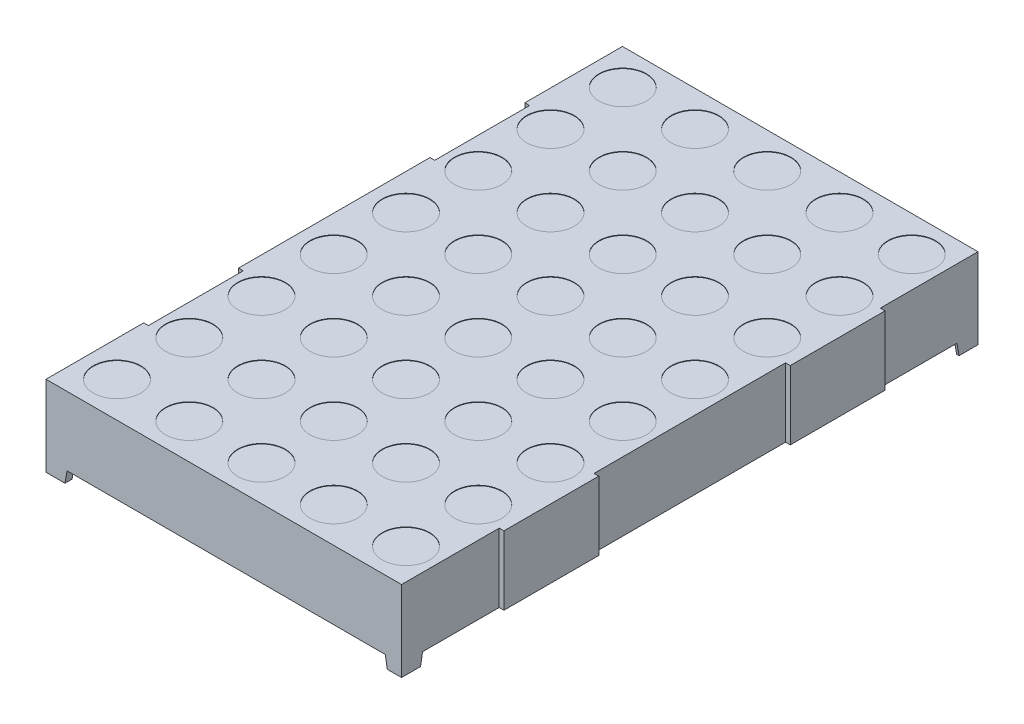
from build123d import *

# Parameters (mm, degrees)
EXTRUDE1_DEPTH     = 19
CUT_EXTRUDE1_DEPTH = 61.8
SKETCH2_R          = 2.5
CUT_EXTRUDE2_DEPTH = 0.05
SKETCH4_R          = 0.25
EXTRUDE2_DEPTH     = 1.25
SKETCH4_3_R        = 0.25
EXTRUDE3_DEPTH     = 4
SKETCH4_4_W        = 1.470408726
SKETCH4_4_H        = 1.470408726
CUT_EXTRUDE3_DEPTH = 1.25
SKETCH2_4_W        = 0.5
SKETCH2_4_H        = 10
SKETCH2_4_H_2      = 10.3
SKETCH2_4_H_3      = 20.2
CUT_EXTRUDE5_DEPTH = 13.5
SKETCH5_W          = 0.025316456
SKETCH5_H          = 0.026582278
SKETCH5_W_2        = 0.025316455
CUT_EXTRUDE6_DEPTH = 0.01


with BuildPart() as part:
    # Sketch1 → Extrude1 (new body, symmetric)
    with BuildSketch(Plane(origin=(0, 0, 0), x_dir=(0, 0, -1), z_dir=(1, 0, 0))):
        Polygon((30.4, 4.25), (-30.4, 4.25), (21.458823529, -3), (28.179591274, -3), (28.34945199, -3.963327992), (30.4, -4.25), align=None)
        Polygon((21.458823529, -3), (-30.4, 4.25), (-30.4, -4.25), (-28.4, -4.25), (-28.179591274, -3), align=None)
        Polygon((30.4, -4.25), (28.34945199, -3.963327992), (28.4, -4.25), align=None)
    extrude(amount=EXTRUDE1_DEPTH, both=True)

    # Sketch3 → Cut-Extrude1 (cut, through all)
    with BuildSketch(Plane.XY.offset(30.4)):
        Polygon((-16.779591274, -3), (-17, -4.25), (17, -4.25), (16.779591274, -3), align=None)
    extrude(amount=-CUT_EXTRUDE1_DEPTH, mode=Mode.SUBTRACT)

    # Sketch2 → Cut-Extrude2 (cut)
    with BuildSketch(Plane(origin=(0, 4.25, 0), x_dir=(-1, 0, 0), z_dir=(0, 1, 0))):
        with Locations(Location((15.24, -19.05, 0), (0, 0, 90))):  # turned: the seam where the file's is
            Circle(SKETCH2_R)
        with Locations(Location((7.62, -19.05, 0), (0, 0, 90))):  # turned: the seam where the file's is
            Circle(SKETCH2_R)
        with Locations(Location((0, -19.05, 0), (0, 0, 90))):  # turned: the seam where the file's is
            Circle(SKETCH2_R)
        with Locations(Location((-7.62, -19.05, 0), (0, 0, 90))):  # turned: the seam where the file's is
            Circle(SKETCH2_R)
        with Locations(Location((-15.24, -19.05, 0), (0, 0, 90))):  # turned: the seam where the file's is
            Circle(SKETCH2_R)
        with Locations(Location((-15.24, -11.43, 0), (0, 0, 90))):  # turned: the seam where the file's is
            Circle(SKETCH2_R)
        with Locations(Location((-7.62, -11.43, 0), (0, 0, 90))):  # turned: the seam where the file's is
            Circle(SKETCH2_R)
        with Locations(Location((0, -11.43, 0), (0, 0, 90))):  # turned: the seam where the file's is
            Circle(SKETCH2_R)
        with Locations(Location((7.62, -11.43, 0), (0, 0, 90))):  # turned: the seam where the file's is
            Circle(SKETCH2_R)
        with Locations(Location((15.24, -11.43, 0), (0, 0, 90))):  # turned: the seam where the file's is
            Circle(SKETCH2_R)
        with Locations(Location((15.24, -3.81, 0), (0, 0, 90))):  # turned: the seam where the file's is
            Circle(SKETCH2_R)
        with Locations(Location((7.62, -3.81, 0), (0, 0, 90))):  # turned: the seam where the file's is
            Circle(SKETCH2_R)
        with Locations(Location((0, -3.81, 0), (0, 0, 90))):  # turned: the seam where the file's is
            Circle(SKETCH2_R)
        with Locations(Location((-7.62, -3.81, 0), (0, 0, 90))):  # turned: the seam where the file's is
            Circle(SKETCH2_R)
        with Locations(Location((-15.24, -3.81, 0), (0, 0, 90))):  # turned: the seam where the file's is
            Circle(SKETCH2_R)
        with Locations(Location((-15.24, 3.81, 0), (0, 0, 90))):  # turned: the seam where the file's is
            Circle(SKETCH2_R)
        with Locations(Location((-7.62, 3.81, 0), (0, 0, 90))):  # turned: the seam where the file's is
            Circle(SKETCH2_R)
        with Locations(Location((0, 3.81, 0), (0, 0, 90))):  # turned: the seam where the file's is
            Circle(SKETCH2_R)
        with Locations(Location((7.62, 3.81, 0), (0, 0, 90))):  # turned: the seam where the file's is
            Circle(SKETCH2_R)
        with Locations(Location((15.24, 3.81, 0), (0, 0, 90))):  # turned: the seam where the file's is
            Circle(SKETCH2_R)
        with Locations(Location((15.24, 11.43, 0), (0, 0, 90))):  # turned: the seam where the file's is
            Circle(SKETCH2_R)
        with Locations(Location((7.62, 11.43, 0), (0, 0, 90))):  # turned: the seam where the file's is
            Circle(SKETCH2_R)
        with Locations(Location((0, 11.43, 0), (0, 0, 90))):  # turned: the seam where the file's is
            Circle(SKETCH2_R)
        with Locations(Location((-7.62, 11.43, 0), (0, 0, 90))):  # turned: the seam where the file's is
            Circle(SKETCH2_R)
        with Locations(Location((-15.24, 11.43, 0), (0, 0, 90))):  # turned: the seam where the file's is
            Circle(SKETCH2_R)
        with Locations(Location((-15.24, 19.05, 0), (0, 0, 90))):  # turned: the seam where the file's is
            Circle(SKETCH2_R)
        with Locations(Location((-7.62, 19.05, 0), (0, 0, 90))):  # turned: the seam where the file's is
            Circle(SKETCH2_R)
        with Locations(Location((0, 19.05, 0), (0, 0, 90))):  # turned: the seam where the file's is
            Circle(SKETCH2_R)
        with Locations(Location((7.62, 19.05, 0), (0, 0, 90))):  # turned: the seam where the file's is
            Circle(SKETCH2_R)
        with Locations(Location((15.24, 19.05, 0), (0, 0, 90))):  # turned: the seam where the file's is
            Circle(SKETCH2_R)
        with Locations(Location((15.24, 26.67, 0), (0, 0, 90))):  # turned: the seam where the file's is
            Circle(SKETCH2_R)
        with Locations(Location((7.62, 26.67, 0), (0, 0, 90))):  # turned: the seam where the file's is
            Circle(SKETCH2_R)
        with Locations(Location((0, 26.67, 0), (0, 0, 90))):  # turned: the seam where the file's is
            Circle(SKETCH2_R)
        with Locations(Location((-7.62, 26.67, 0), (0, 0, 90))):  # turned: the seam where the file's is
            Circle(SKETCH2_R)
        with Locations(Location((-15.24, 26.67, 0), (0, 0, 90))):  # turned: the seam where the file's is
            Circle(SKETCH2_R)
        with Locations(Location((15.24, -26.67, 0), (0, 0, 90))):  # turned: the seam where the file's is
            Circle(SKETCH2_R)
        with Locations(Location((7.62, -26.67, 0), (0, 0, 90))):  # turned: the seam where the file's is
            Circle(SKETCH2_R)
        with Locations(Location((0, -26.67, 0), (0, 0, 90))):  # turned: the seam where the file's is
            Circle(SKETCH2_R)
        with Locations(Location((-7.62, -26.67, 0), (0, 0, 90))):  # turned: the seam where the file's is
            Circle(SKETCH2_R)
        with Locations(Location((-15.24, -26.67, 0), (0, 0, 90))):  # turned: the seam where the file's is
            Circle(SKETCH2_R)
    extrude(amount=-CUT_EXTRUDE2_DEPTH, mode=Mode.SUBTRACT)

    # Sketch4 → Extrude2 (add)
    with BuildSketch(Plane.XZ.offset(4.25)):
        with Locations(Location((-7.62, 22.86, 0), (0, 0, 270))):  # turned: the seam where the file's is
            Circle(SKETCH4_R)
        with Locations(Location((-5.08, 22.86, 0), (0, 0, 270))):  # turned: the seam where the file's is
            Circle(SKETCH4_R)
        with Locations(Location((-2.54, 22.86, 0), (0, 0, 270))):  # turned: the seam where the file's is
            Circle(SKETCH4_R)
        with Locations(Location((7.62, 22.86, 0), (0, 0, 270))):  # turned: the seam where the file's is
            Circle(SKETCH4_R)
        with Locations(Location((0, 22.86, 0), (0, 0, 270))):  # turned: the seam where the file's is
            Circle(SKETCH4_R)
        with Locations(Location((2.54, 22.86, 0), (0, 0, 270))):  # turned: the seam where the file's is
            Circle(SKETCH4_R)
        with Locations(Location((5.08, 22.86, 0), (0, 0, 270))):  # turned: the seam where the file's is
            Circle(SKETCH4_R)
        with Locations(Location((5.08, -22.86, 0), (0, 0, 270))):  # turned: the seam where the file's is
            Circle(SKETCH4_R)
        with Locations(Location((2.54, -22.86, 0), (0, 0, 270))):  # turned: the seam where the file's is
            Circle(SKETCH4_R)
        with Locations(Location((0, -22.86, 0), (0, 0, 270))):  # turned: the seam where the file's is
            Circle(SKETCH4_R)
        with Locations(Location((7.62, -22.86, 0), (0, 0, 270))):  # turned: the seam where the file's is
            Circle(SKETCH4_R)
        with Locations(Location((-2.54, -22.86, 0), (0, 0, 270))):  # turned: the seam where the file's is
            Circle(SKETCH4_R)
        with Locations(Location((-5.08, -22.86, 0), (0, 0, 270))):  # turned: the seam where the file's is
            Circle(SKETCH4_R)
        with Locations(Location((-7.62, -22.86, 0), (0, 0, 270))):  # turned: the seam where the file's is
            Circle(SKETCH4_R)
        with Locations(Location((10.16, 22.86, 0), (0, 0, 270))):  # turned: the seam where the file's is
            Circle(SKETCH4_R)
        with Locations(Location((-10.16, 22.86, 0), (0, 0, 270))):  # turned: the seam where the file's is
            Circle(SKETCH4_R)
        with Locations(Location((-10.16, -22.86, 0), (0, 0, 270))):  # turned: the seam where the file's is
            Circle(SKETCH4_R)
        with Locations(Location((10.16, -22.86, 0), (0, 0, 270))):  # turned: the seam where the file's is
            Circle(SKETCH4_R)
    extrude(amount=-EXTRUDE2_DEPTH)

    # Sketch4_3 → Extrude3 (add)
    with BuildSketch(Plane.XZ.offset(4.25)):
        with Locations(Location((-7.62, 22.86, 0), (0, 0, 270))):  # turned: the seam where the file's is
            Circle(SKETCH4_3_R)
        with Locations(Location((-5.08, 22.86, 0), (0, 0, 270))):  # turned: the seam where the file's is
            Circle(SKETCH4_3_R)
        with Locations(Location((-2.54, 22.86, 0), (0, 0, 270))):  # turned: the seam where the file's is
            Circle(SKETCH4_3_R)
        with Locations(Location((7.62, 22.86, 0), (0, 0, 270))):  # turned: the seam where the file's is
            Circle(SKETCH4_3_R)
        with Locations(Location((0, 22.86, 0), (0, 0, 270))):  # turned: the seam where the file's is
            Circle(SKETCH4_3_R)
        with Locations(Location((2.54, 22.86, 0), (0, 0, 270))):  # turned: the seam where the file's is
            Circle(SKETCH4_3_R)
        with Locations(Location((5.08, 22.86, 0), (0, 0, 270))):  # turned: the seam where the file's is
            Circle(SKETCH4_3_R)
        with Locations(Location((5.08, -22.86, 0), (0, 0, 270))):  # turned: the seam where the file's is
            Circle(SKETCH4_3_R)
        with Locations(Location((2.54, -22.86, 0), (0, 0, 270))):  # turned: the seam where the file's is
            Circle(SKETCH4_3_R)
        with Locations(Location((0, -22.86, 0), (0, 0, 270))):  # turned: the seam where the file's is
            Circle(SKETCH4_3_R)
        with Locations(Location((7.62, -22.86, 0), (0, 0, 270))):  # turned: the seam where the file's is
            Circle(SKETCH4_3_R)
        with Locations(Location((-2.54, -22.86, 0), (0, 0, 270))):  # turned: the seam where the file's is
            Circle(SKETCH4_3_R)
        with Locations(Location((-5.08, -22.86, 0), (0, 0, 270))):  # turned: the seam where the file's is
            Circle(SKETCH4_3_R)
        with Locations(Location((-7.62, -22.86, 0), (0, 0, 270))):  # turned: the seam where the file's is
            Circle(SKETCH4_3_R)
        with Locations(Location((10.16, 22.86, 0), (0, 0, 270))):  # turned: the seam where the file's is
            Circle(SKETCH4_3_R)
        with Locations(Location((-10.16, 22.86, 0), (0, 0, 270))):  # turned: the seam where the file's is
            Circle(SKETCH4_3_R)
        with Locations(Location((-10.16, -22.86, 0), (0, 0, 270))):  # turned: the seam where the file's is
            Circle(SKETCH4_3_R)
        with Locations(Location((10.16, -22.86, 0), (0, 0, 270))):  # turned: the seam where the file's is
            Circle(SKETCH4_3_R)
    extrude(amount=EXTRUDE3_DEPTH)

    # Sketch4_4 → Cut-Extrude3 (cut)
    with BuildSketch(Plane.XZ.offset(4.25)):
        with Locations((-17.514795637, 28.914795637)):
            Rectangle(SKETCH4_4_W, SKETCH4_4_H)
        with Locations((17.514795637, 28.914795637)):
            Rectangle(SKETCH4_4_W, SKETCH4_4_H)
        with Locations((17.514795637, -28.914795637)):
            Rectangle(SKETCH4_4_W, SKETCH4_4_H)
        with Locations((-17.514795637, -28.914795637)):
            Rectangle(SKETCH4_4_W, SKETCH4_4_H)
    extrude(amount=-CUT_EXTRUDE3_DEPTH, mode=Mode.SUBTRACT)

    # Sketch2_4 → Cut-Extrude5 (cut, through all)
    with BuildSketch(Plane(origin=(0, 4.25, 0), x_dir=(-1, 0, 0), z_dir=(0, 1, 0))):
        with Locations((18.75, -15.1)):
            Rectangle(SKETCH2_4_W, SKETCH2_4_H)
        with Locations((18.75, 15.1)):
            Rectangle(SKETCH2_4_W, SKETCH2_4_H)
        with Locations((-18.75, 25.25)):
            Rectangle(SKETCH2_4_W, SKETCH2_4_H_2)
        with Locations((-18.75, 0)):
            Rectangle(SKETCH2_4_W, SKETCH2_4_H_3)
        with Locations((-18.75, -25.25)):
            Rectangle(SKETCH2_4_W, SKETCH2_4_H_2)
    extrude(amount=-CUT_EXTRUDE5_DEPTH, mode=Mode.SUBTRACT)

    # Sketch5 → Cut-Extrude6 (cut)
    with BuildSketch(Plane.XZ.offset(3)):
        Polygon((0.896484083, 19.016590926), (0.919941361, 19.09127447), (0.944684241, 19.09127447), (0.96110038, 19.040938236), (0.976626488, 19.09127447), (1.002358292, 19.09127447), (1.025598007, 19.016590926), (1.000420001, 19.016590926), (0.987425539, 19.068074312), (0.971009399, 19.016590926), (0.949510191, 19.016590926), (0.933192944, 19.068074312), (0.920376488, 19.016590926), align=None)
        Polygon((0.762306868, 19.016590926), (0.785764146, 19.09127447), (0.810507026, 19.09127447), (0.826923165, 19.040938236), (0.842449273, 19.09127447), (0.868181077, 19.09127447), (0.891420792, 19.016590926), (0.866242785, 19.016590926), (0.853248323, 19.068074312), (0.836832184, 19.016590926), (0.815332975, 19.016590926), (0.799015728, 19.068074312), (0.786199273, 19.016590926), align=None)
        Polygon((0.628129653, 19.016590926), (0.651586931, 19.09127447), (0.676329811, 19.09127447), (0.69274595, 19.040938236), (0.708272058, 19.09127447), (0.734003861, 19.09127447), (0.757243577, 19.016590926), (0.73206557, 19.016590926), (0.719071108, 19.068074312), (0.702654969, 19.016590926), (0.68115576, 19.016590926), (0.664838513, 19.068074312), (0.652022058, 19.016590926), align=None)
        with Locations((0.600281551, 19.077983331)):
            Rectangle(SKETCH5_W, SKETCH5_H)
        with BuildLine():
            add(Edge.make_bspline(
                [(0.483825855, 19.060103584), (0.483862383, 19.061325698), (0.483934112, 19.063725522), (0.484543274, 19.067233488), (0.485538799, 19.070556771), (0.486903137, 19.073719487), (0.488717125, 19.076674853), (0.490872138, 19.07949342), (0.493484053, 19.082077382), (0.496421089, 19.084516143), (0.499719017, 19.086698538), (0.503321638, 19.088598676), (0.507191958, 19.090223395), (0.511345979, 19.091555085), (0.515791556, 19.092545852), (0.520509333, 19.093269169), (0.525502682, 19.093742677), (0.52892627, 19.093784618), (0.530681077, 19.093806116)],
                knots=[0, 0, 0, 0, 0.907421153, 1.781872267, 2.635683434, 3.480115191, 4.332689235, 5.205575272, 6.109500117, 7.055808355, 8.037942167, 9.041423561, 10.07750834, 11.152467461, 12.277657752, 13.45734338, 14.696726425, 16, 16, 16, 16], degree=3))
            add(Edge.make_bspline(
                [(0.530681077, 19.093806116), (0.532699061, 19.093778851), (0.536607247, 19.093726047), (0.542274815, 19.093340674), (0.547538282, 19.092652724), (0.552436029, 19.091696144), (0.55704033, 19.090492859), (0.561473674, 19.089202215), (0.565754966, 19.087737634), (0.568528058, 19.086637498), (0.569901804, 19.086092508)],
                knots=[0, 0, 0, 0, 1.203182053, 2.33017619, 3.384818652, 4.366208123, 5.30340534, 6.221361684, 7.118890722, 8, 8, 8, 8], degree=3))
            Line((0.569901804, 19.086092508), (0.569901804, 19.062160546))
            Line((0.569901804, 19.062160546), (0.567053703, 19.062160546))
            add(Edge.make_bspline(
                [(0.567053703, 19.062160546), (0.56568814, 19.063241509), (0.56296503, 19.065397088), (0.558538072, 19.068165442), (0.55387906, 19.070538453), (0.549040667, 19.072521075), (0.544139298, 19.074096689), (0.539270231, 19.075223595), (0.534501248, 19.075962959), (0.531342926, 19.07604452), (0.529791045, 19.076084597)],
                knots=[0, 0, 0, 0, 1.030738938, 2.055426519, 3.085610749, 4.123842265, 5.148648843, 6.130724483, 7.081507926, 8, 8, 8, 8], degree=3))
            add(Edge.make_bspline(
                [(0.529791045, 19.076084597), (0.529362299, 19.076083296), (0.528444386, 19.076080511), (0.526975238, 19.075959196), (0.525318895, 19.075831352), (0.523538157, 19.075635238), (0.521750952, 19.075404093), (0.520090704, 19.075057626), (0.518589943, 19.074688475), (0.517683273, 19.074321209), (0.517251488, 19.074146305)],
                knots=[0, 0, 0, 0, 0.806537132, 1.726733348, 2.77251655, 3.932999672, 5.098049949, 6.161349231, 7.124375527, 8, 8, 8, 8], degree=3))
            add(Edge.make_bspline(
                [(0.517251488, 19.074146305), (0.516772002, 19.07391807), (0.515829709, 19.073469538), (0.514527179, 19.072655628), (0.513356693, 19.071760883), (0.512295991, 19.07079915), (0.511433596, 19.069636162), (0.510812435, 19.068236891), (0.510467864, 19.066587598), (0.510428792, 19.065412437), (0.510408134, 19.064791084)],
                knots=[0, 0, 0, 0, 1.02474257, 2.013837243, 2.958431669, 3.867978675, 4.769292696, 5.732237074, 6.800947934, 8, 8, 8, 8], degree=3))
            add(Edge.make_bspline(
                [(0.510408134, 19.064791084), (0.510439595, 19.064245218), (0.510501457, 19.063171884), (0.511082963, 19.061643454), (0.51196701, 19.060223318), (0.513246426, 19.058957982), (0.514860104, 19.05783187), (0.516791091, 19.056821107), (0.519064941, 19.055985349), (0.520702154, 19.055547477), (0.521563197, 19.055317192)],
                knots=[0, 0, 0, 0, 0.825427492, 1.623033598, 2.45033906, 3.348940377, 4.33183287, 5.428402891, 6.647546779, 8, 8, 8, 8], degree=3))
            add(Edge.make_bspline(
                [(0.521563197, 19.055317192), (0.523532438, 19.054871987), (0.527567649, 19.053959709), (0.533707462, 19.052772255), (0.539846165, 19.051546384), (0.543802422, 19.050332069), (0.545732501, 19.04973966)],
                knots=[0, 0, 0, 0, 0.976118991, 2.000185432, 3.024380873, 4, 4, 4, 4], degree=3))
            add(Edge.make_bspline(
                [(0.545732501, 19.04973966), (0.546770653, 19.049385937), (0.548791515, 19.048697383), (0.551690707, 19.047544734), (0.554333955, 19.0462396), (0.556791494, 19.044917562), (0.558984158, 19.043437504), (0.560978792, 19.041904745), (0.562731453, 19.04025194), (0.56425789, 19.038502448), (0.565600756, 19.036666086), (0.566754166, 19.034718945), (0.567715189, 19.032652495), (0.56853858, 19.030497098), (0.569149807, 19.028222563), (0.569572243, 19.025846146), (0.569870306, 19.023362659), (0.569891162, 19.021668324), (0.569901804, 19.020803742)],
                knots=[0, 0, 0, 0, 1.287376879, 2.505999703, 3.65855109, 4.746193839, 5.778582289, 6.760029101, 7.696159662, 8.601061861, 9.48181646, 10.363080883, 11.252765705, 12.153987336, 13.068239035, 14.012364187, 14.985753787, 16, 16, 16, 16], degree=3))
            add(Edge.make_bspline(
                [(0.569901804, 19.020803742), (0.569864504, 19.019647596), (0.569791098, 19.017372321), (0.569189647, 19.014043299), (0.568163137, 19.01089448), (0.566776777, 19.007891324), (0.564949284, 19.00507706), (0.562757162, 19.002399574), (0.560146851, 18.999907078), (0.557161524, 18.997608441), (0.553874677, 18.995529636), (0.550340672, 18.993692928), (0.54656182, 18.992186481), (0.542581935, 18.99090525), (0.538362543, 18.989952854), (0.533925572, 18.989233277), (0.52925171, 18.988820276), (0.526060299, 18.988769001), (0.524431077, 18.988742824)],
                knots=[0, 0, 0, 0, 0.894901293, 1.761149761, 2.608783409, 3.453876344, 4.314933854, 5.200038827, 6.12799933, 7.103249695, 8.113098521, 9.136064399, 10.182719798, 11.259667356, 12.370545059, 13.528828137, 14.738461593, 16, 16, 16, 16], degree=3))
            add(Edge.make_bspline(
                [(0.524431077, 18.988742824), (0.522762425, 18.988765217), (0.519427951, 18.988809965), (0.514445978, 18.989184934), (0.509488564, 18.989751436), (0.504617, 18.99055089), (0.499934492, 18.991568546), (0.495517879, 18.992654504), (0.491438908, 18.993894894), (0.488865183, 18.994848939), (0.487623323, 18.99530928)],
                knots=[0, 0, 0, 0, 1.065379838, 2.128953261, 3.188461447, 4.250817766, 5.279613205, 6.247547721, 7.154416075, 8, 8, 8, 8], degree=3))
            Line((0.487623323, 18.99530928), (0.487623323, 19.017856749))
            Line((0.487623323, 19.017856749), (0.490451646, 19.017856749))
            add(Edge.make_bspline(
                [(0.490451646, 19.017856749), (0.491524606, 19.017056545), (0.493718836, 19.015420107), (0.497377589, 19.01333413), (0.501341649, 19.011384616), (0.505606551, 19.009662823), (0.510079091, 19.008242222), (0.514656637, 19.007213178), (0.519283702, 19.006574055), (0.522385293, 19.006500922), (0.523936615, 19.006464343)],
                knots=[0, 0, 0, 0, 0.89224925, 1.824673196, 2.804309561, 3.838364047, 4.890042674, 5.931526337, 6.965412421, 8, 8, 8, 8], degree=3))
            add(Edge.make_bspline(
                [(0.523936615, 19.006464343), (0.525031914, 19.006488553), (0.52722166, 19.006536954), (0.530496067, 19.006886208), (0.533730859, 19.007557949), (0.535773757, 19.008372286), (0.536792627, 19.008778426)],
                knots=[0, 0, 0, 0, 0.998993879, 1.997209027, 3.00113285, 4, 4, 4, 4], degree=3))
            add(Edge.make_bspline(
                [(0.536792627, 19.008778426), (0.537226106, 19.008979908), (0.538092776, 19.00938274), (0.539299779, 19.010155065), (0.540403083, 19.011084783), (0.541404088, 19.012137177), (0.542252144, 19.013306512), (0.542889804, 19.014576271), (0.543250624, 19.01593825), (0.54329646, 19.016872418), (0.543319526, 19.017342508)],
                knots=[0, 0, 0, 0, 1.005454979, 2.010239304, 3.005296729, 4.036100111, 5.060531193, 6.034954812, 7.011155677, 8, 8, 8, 8], degree=3))
            add(Edge.make_bspline(
                [(0.543319526, 19.017342508), (0.543284732, 19.017980439), (0.543218243, 19.019199467), (0.542618245, 19.020913163), (0.541620576, 19.022376275), (0.540467478, 19.023369268), (0.539350498, 19.024068028), (0.538309981, 19.024573268), (0.53711053, 19.025086691), (0.535733081, 19.025575888), (0.534197946, 19.026069934), (0.532489024, 19.026544604), (0.530606417, 19.026994163), (0.529290526, 19.027280315), (0.528604336, 19.027429533)],
                knots=[0, 0, 0, 0, 1.174343879, 2.244064321, 3.303704314, 4.407076671, 5.02483983, 5.732197225, 6.53898402, 7.431906431, 8.428480183, 9.514816237, 10.704066255, 12, 12, 12, 12], degree=3))
            add(Edge.make_bspline(
                [(0.528604336, 19.027429533), (0.526771711, 19.027806253), (0.523171009, 19.028546425), (0.517765933, 19.029640722), (0.512272879, 19.030953239), (0.508602329, 19.032082452), (0.506689779, 19.032670831)],
                knots=[0, 0, 0, 0, 0.995788186, 1.956503735, 2.935230479, 4, 4, 4, 4], degree=3))
            add(Edge.make_bspline(
                [(0.506689779, 19.032670831), (0.505743223, 19.032990072), (0.503891605, 19.03361456), (0.501251007, 19.034700878), (0.498803834, 19.035874735), (0.4965372, 19.037116705), (0.494461834, 19.038459138), (0.492575544, 19.039884471), (0.490877587, 19.041389254), (0.489388839, 19.043004974), (0.488060081, 19.044715322), (0.486947738, 19.046565935), (0.485952152, 19.048509464), (0.485198997, 19.050602907), (0.484574488, 19.052801435), (0.484152745, 19.055133369), (0.483858382, 19.057577587), (0.483836818, 19.059252186), (0.483825855, 19.060103584)],
                knots=[0, 0, 0, 0, 1.237326419, 2.420410185, 3.534642089, 4.598489486, 5.620241961, 6.59385002, 7.525152549, 8.426792174, 9.312230456, 10.203151844, 11.098070343, 12.012931196, 12.954244379, 13.926618287, 14.945853925, 16, 16, 16, 16], degree=3))
        make_face()
        with BuildLine():
            Line((0.391420792, 19.09127447), (0.415471425, 19.09127447))
            Line((0.415471425, 19.09127447), (0.415471425, 19.083442192))
            add(Edge.make_bspline(
                [(0.415471425, 19.083442192), (0.416564618, 19.084250986), (0.41867228, 19.085810331), (0.421846839, 19.087887393), (0.424865139, 19.089671815), (0.427795491, 19.091194932), (0.430801768, 19.092407103), (0.434039903, 19.093225484), (0.437541498, 19.093728208), (0.439968568, 19.093779569), (0.441223007, 19.093806116)],
                knots=[0, 0, 0, 0, 1.150945962, 2.219006967, 3.209666795, 4.118194914, 5.012574058, 5.946577101, 6.93868214, 8, 8, 8, 8], degree=3))
            add(Edge.make_bspline(
                [(0.441223007, 19.093806116), (0.442239282, 19.093783168), (0.444218263, 19.093738482), (0.447096562, 19.093396761), (0.449798529, 19.092848352), (0.452327365, 19.092079945), (0.454677065, 19.091076914), (0.456820745, 19.08980528), (0.458823322, 19.088372566), (0.460605269, 19.0866662), (0.462220816, 19.084768282), (0.463603386, 19.082635873), (0.464781091, 19.080302933), (0.465722191, 19.077751083), (0.46647728, 19.074992779), (0.467001212, 19.072013531), (0.467321805, 19.068826404), (0.467353744, 19.066631274), (0.467370159, 19.065503109)],
                knots=[0, 0, 0, 0, 1.108959949, 2.159465255, 3.158589008, 4.114545495, 5.039534357, 5.93921201, 6.830099133, 7.720870013, 8.624681761, 9.544731627, 10.487599671, 11.471264588, 12.508152322, 13.604835107, 14.769030043, 16, 16, 16, 16], degree=3))
            Line((0.467370159, 19.065503109), (0.467370159, 19.016590926))
            Line((0.467370159, 19.016590926), (0.443319526, 19.016590926))
            Line((0.443319526, 19.016590926), (0.443319526, 19.05417004))
            add(Edge.make_bspline(
                [(0.443319526, 19.05417004), (0.44331789, 19.055086511), (0.44331476, 19.056840726), (0.443232421, 19.059346533), (0.44311152, 19.061614705), (0.442972816, 19.063656734), (0.442719799, 19.065503485), (0.44234209, 19.067169646), (0.441871264, 19.068689248), (0.441406946, 19.069595949), (0.44118345, 19.070032381)],
                knots=[0, 0, 0, 0, 1.361401701, 2.605856924, 3.723918663, 4.735739235, 5.645738665, 6.489217889, 7.27279937, 8, 8, 8, 8], degree=3))
            add(Edge.make_bspline(
                [(0.44118345, 19.070032381), (0.440953442, 19.070431087), (0.440501265, 19.071214908), (0.439581, 19.07222122), (0.438502158, 19.07306497), (0.437224954, 19.073723071), (0.435735387, 19.074213574), (0.434014529, 19.074594145), (0.432022787, 19.074766023), (0.430615319, 19.074800513), (0.429870159, 19.074818774)],
                knots=[0, 0, 0, 0, 0.849004071, 1.669068917, 2.503060811, 3.370079215, 4.310762265, 5.396376419, 6.621555549, 8, 8, 8, 8], degree=3))
            add(Edge.make_bspline(
                [(0.429870159, 19.074818774), (0.429329216, 19.074798935), (0.4282178, 19.074758173), (0.426500347, 19.074566632), (0.424711087, 19.074167474), (0.422192418, 19.073522529), (0.419027209, 19.072328675), (0.416667675, 19.070975528), (0.415471425, 19.070289502)],
                knots=[0, 0, 0, 0, 0.638062719, 1.310959128, 2.033463623, 2.796942592, 4.376095945, 6, 6, 6, 6], degree=3))
            Line((0.415471425, 19.070289502), (0.415471425, 19.016590926))
            Line((0.415471425, 19.016590926), (0.391420792, 19.016590926))
            Line((0.391420792, 19.016590926), (0.391420792, 19.09127447))
        make_face()
        with BuildLine():
            Line((0.293952437, 19.09127447), (0.31800307, 19.09127447))
            Line((0.31800307, 19.09127447), (0.31800307, 19.053695356))
            add(Edge.make_bspline(
                [(0.31800307, 19.053695356), (0.318028077, 19.052165367), (0.318078048, 19.049107875), (0.318354599, 19.045344781), (0.318739086, 19.042503242), (0.319106626, 19.040671653), (0.319538497, 19.039123536), (0.319950758, 19.038237775), (0.320139146, 19.037833014)],
                knots=[0, 0, 0, 0, 1.709111167, 3.415443484, 4.21113913, 4.910175115, 5.501990373, 6, 6, 6, 6], degree=3))
            add(Edge.make_bspline(
                [(0.320139146, 19.037833014), (0.320383607, 19.037434951), (0.320862907, 19.036654493), (0.321800258, 19.035641617), (0.322894041, 19.034812248), (0.324165217, 19.034132781), (0.325653326, 19.033653593), (0.327377244, 19.033300839), (0.329357428, 19.033090285), (0.330766257, 19.033061732), (0.331511773, 19.033046622)],
                knots=[0, 0, 0, 0, 0.860202684, 1.686548532, 2.528236983, 3.382486038, 4.33249885, 5.401154041, 6.624757403, 8, 8, 8, 8], degree=3))
            add(Edge.make_bspline(
                [(0.331511773, 19.033046622), (0.332642662, 19.033106723), (0.334950357, 19.033229364), (0.337825667, 19.03389603), (0.340143005, 19.034755994), (0.342000722, 19.03550643), (0.343908444, 19.036480531), (0.345187986, 19.037201972), (0.345851172, 19.037575894)],
                knots=[0, 0, 0, 0, 1.33818541, 2.730705359, 3.468371228, 4.262126284, 5.099261778, 6, 6, 6, 6], degree=3))
            Line((0.345851172, 19.037575894), (0.345851172, 19.09127447))
            Line((0.345851172, 19.09127447), (0.369901804, 19.09127447))
            Line((0.369901804, 19.09127447), (0.369901804, 19.016590926))
            Line((0.369901804, 19.016590926), (0.345851172, 19.016590926))
            Line((0.345851172, 19.016590926), (0.345851172, 19.024423204))
            add(Edge.make_bspline(
                [(0.345851172, 19.024423204), (0.344793765, 19.023617053), (0.34273546, 19.02204783), (0.339556223, 19.02000741), (0.336472325, 19.018208641), (0.333419315, 19.016695824), (0.33030436, 19.015489049), (0.327041601, 19.01467806), (0.323625195, 19.014134257), (0.32128848, 19.014084564), (0.320099589, 19.01405928)],
                knots=[0, 0, 0, 0, 1.126119141, 2.192057864, 3.198061997, 4.149848529, 5.076251285, 6.021887753, 6.99356175, 8, 8, 8, 8], degree=3))
            add(Edge.make_bspline(
                [(0.320099589, 19.01405928), (0.319103324, 19.014084681), (0.317158438, 19.014134267), (0.314323588, 19.014443819), (0.311652482, 19.014995041), (0.309159098, 19.015790898), (0.306823411, 19.016782257), (0.304649739, 19.017986237), (0.30266389, 19.019449518), (0.300835738, 19.021109456), (0.299196638, 19.023000754), (0.297799729, 19.025130132), (0.296595367, 19.027467052), (0.295646101, 19.030029689), (0.294854777, 19.032795961), (0.294350014, 19.035794591), (0.293992361, 19.039004477), (0.293966011, 19.041220627), (0.293952437, 19.042362286)],
                knots=[0, 0, 0, 0, 1.08828964, 2.12453497, 3.110382522, 4.062402335, 4.978696626, 5.878225494, 6.769849763, 7.667011675, 8.57076823, 9.495541561, 10.442454184, 11.436213583, 12.475881554, 13.580560132, 14.753614518, 16, 16, 16, 16], degree=3))
            Line((0.293952437, 19.042362286), (0.293952437, 19.09127447))
        make_face()
        Polygon((0.199015728, 19.09127447), (0.271167627, 19.09127447), (0.271167627, 18.99127447), (0.245851172, 18.99127447), (0.245851172, 19.072287128), (0.199015728, 19.072287128), align=None)
        Polygon((0.111673956, 19.09127447), (0.183825855, 19.09127447), (0.183825855, 18.99127447), (0.111673956, 18.99127447), (0.111673956, 19.010261812), (0.158509399, 19.010261812), (0.158509399, 19.027983331), (0.115471425, 19.027983331), (0.115471425, 19.046970673), (0.158509399, 19.046970673), (0.158509399, 19.072287128), (0.111673956, 19.072287128), align=None)
        with BuildLine():
            add(Edge.make_bspline(
                [(-0.00478174, 19.041373362), (-0.004762425, 19.042521051), (-0.004724172, 19.044793937), (-0.004428981, 19.048158744), (-0.003902956, 19.05142442), (-0.003223774, 19.054608668), (-0.002301269, 19.057687596), (-0.001219555, 19.060695173), (9.0091e-05, 19.063600666), (0.001594944, 19.066402101), (0.003244416, 19.069074204), (0.005019165, 19.071594412), (0.006864944, 19.07397763), (0.008854257, 19.076172524), (0.010933438, 19.078214544), (0.013108967, 19.080105358), (0.015414031, 19.081808789), (0.017021194, 19.082831673), (0.017825064, 19.083343299)],
                knots=[0, 0, 0, 0, 1.105570398, 2.18947457, 3.250358341, 4.290584537, 5.323553275, 6.344225964, 7.367641686, 8.3905646, 9.405808457, 10.390761353, 11.358902336, 12.307789878, 13.241960776, 14.165076779, 15.082208636, 16, 16, 16, 16], degree=3))
            add(Edge.make_bspline(
                [(0.017825064, 19.083343299), (0.019064251, 19.08405562), (0.021548948, 19.085483897), (0.025533406, 19.087149736), (0.029655015, 19.088563959), (0.034014196, 19.0895774), (0.038652917, 19.090347235), (0.043657728, 19.090895406), (0.049064635, 19.091200909), (0.052799627, 19.091249391), (0.054731709, 19.09127447)],
                knots=[0, 0, 0, 0, 0.896321744, 1.797216976, 2.705381885, 3.628777036, 4.602292017, 5.655629376, 6.787275635, 8, 8, 8, 8], degree=3))
            Line((0.054731709, 19.09127447), (0.090154969, 19.09127447))
            Line((0.090154969, 19.09127447), (0.090154969, 18.99127447))
            Line((0.090154969, 18.99127447), (0.053723007, 18.99127447))
            add(Edge.make_bspline(
                [(0.053723007, 18.99127447), (0.051744311, 18.99129128), (0.047927651, 18.991323705), (0.042410335, 18.991738632), (0.037307997, 18.992344395), (0.032618417, 18.993238581), (0.028315967, 18.994353162), (0.024398676, 18.995741693), (0.020782442, 18.99723431), (0.018603907, 18.998508864), (0.017548165, 18.999126527)],
                knots=[0, 0, 0, 0, 1.267083275, 2.444046388, 3.541868212, 4.55639609, 5.499737919, 6.385160515, 7.217431253, 8, 8, 8, 8], degree=3))
            add(Edge.make_bspline(
                [(0.017548165, 18.999126527), (0.016697212, 18.999663068), (0.015005087, 19.000729981), (0.012603873, 19.002511834), (0.010374445, 19.00446791), (0.008245943, 19.006519729), (0.006266125, 19.008722616), (0.004422925, 19.011061323), (0.002719108, 19.013539417), (0.001161145, 19.016148886), (-0.00025967, 19.018878938), (-0.001448976, 19.021751997), (-0.002498325, 19.024730527), (-0.003303861, 19.027839489), (-0.004001776, 19.031047326), (-0.00443651, 19.03438867), (-0.004723121, 19.037841158), (-0.004762036, 19.040186048), (-0.00478174, 19.041373362)],
                knots=[0, 0, 0, 0, 0.964065863, 1.917049184, 2.86229036, 3.805247319, 4.749389377, 5.698846072, 6.657678277, 7.629829384, 8.610569287, 9.604676042, 10.607940105, 11.6349849, 12.681042988, 13.752616828, 14.862056989, 16, 16, 16, 16], degree=3))
        make_face()
        with BuildLine():
            add(Edge.make_bspline(
                [(0.021800539, 19.041215135), (0.021843841, 19.039636704), (0.021927454, 19.036588905), (0.022632848, 19.032193261), (0.023772098, 19.028150311), (0.025109791, 19.025037895), (0.026447182, 19.022764577), (0.027574706, 19.021166307), (0.028824372, 19.019652107), (0.030214981, 19.018243267), (0.031750165, 19.016936231), (0.033411424, 19.01570732), (0.035211465, 19.014578675), (0.036484497, 19.013918669), (0.037128861, 19.013584597)],
                knots=[0, 0, 0, 0, 1.694683197, 3.272273219, 4.767406206, 6.197615014, 6.895990032, 7.597410435, 8.296503208, 9.002591366, 9.720792421, 10.460154445, 11.220583224, 12, 12, 12, 12], degree=3))
            add(Edge.make_bspline(
                [(0.037128861, 19.013584597), (0.037803796, 19.013278082), (0.039141565, 19.01267055), (0.04121184, 19.011936463), (0.043304542, 19.011374136), (0.045498769, 19.010901713), (0.047975529, 19.010624577), (0.05089802, 19.010411901), (0.054354693, 19.010274973), (0.056841289, 19.010266402), (0.058173165, 19.010261812)],
                knots=[0, 0, 0, 0, 0.826913061, 1.638999358, 2.447478739, 3.243919028, 4.140906711, 5.225381046, 6.513851968, 8, 8, 8, 8], degree=3))
            Line((0.058173165, 19.010261812), (0.064838513, 19.010261812))
            Line((0.064838513, 19.010261812), (0.064838513, 19.072287128))
            Line((0.064838513, 19.072287128), (0.058173165, 19.072287128))
            add(Edge.make_bspline(
                [(0.058173165, 19.072287128), (0.057414974, 19.072282083), (0.055951239, 19.072272342), (0.053834785, 19.072233239), (0.051870024, 19.072172922), (0.050062673, 19.07210108), (0.048406536, 19.071986177), (0.046918702, 19.07181758), (0.045576352, 19.071673193), (0.044008718, 19.071406073), (0.042155569, 19.070989618), (0.039994303, 19.070311526), (0.03785377, 19.069461107), (0.036465197, 19.068776143), (0.035764146, 19.068430324)],
                knots=[0, 0, 0, 0, 1.186775798, 2.291144404, 3.313233901, 4.263515562, 5.122260739, 5.910868134, 6.60717912, 7.234883681, 8.398964994, 9.577230746, 10.776813768, 12, 12, 12, 12], degree=3))
            add(Edge.make_bspline(
                [(0.035764146, 19.068430324), (0.035180432, 19.068086848), (0.034032495, 19.067411364), (0.032388351, 19.066305502), (0.030901611, 19.065070502), (0.02949555, 19.063787404), (0.028242683, 19.06239695), (0.02706939, 19.06094647), (0.026059134, 19.059384077), (0.024814139, 19.057190548), (0.023594407, 19.054157178), (0.022553647, 19.050190635), (0.021917132, 19.045830625), (0.021840399, 19.042793043), (0.021800539, 19.041215135)],
                knots=[0, 0, 0, 0, 0.755109416, 1.485004392, 2.205961541, 2.908125208, 3.605307969, 4.290649036, 4.985852759, 5.676964147, 7.100721462, 8.614478074, 10.241350405, 12, 12, 12, 12], degree=3))
        make_face(mode=Mode.SUBTRACT)
        with Locations((-0.03642731, 19.077983331)):
            Rectangle(SKETCH5_W_2, SKETCH5_H)
        with BuildLine():
            add(Edge.make_bspline(
                [(-0.111071297, 19.093806116), (-0.109481191, 19.093784289), (-0.106360069, 19.093741448), (-0.101788625, 19.093264746), (-0.097423821, 19.092546279), (-0.093276203, 19.091528107), (-0.089369642, 19.090171765), (-0.085688588, 19.08855375), (-0.082299226, 19.086535944), (-0.080235496, 19.084959003), (-0.079208164, 19.084173995)],
                knots=[0, 0, 0, 0, 1.123606455, 2.205459211, 3.245124445, 4.248821949, 5.220056174, 6.165006393, 7.086533249, 8, 8, 8, 8], degree=3))
            add(Edge.make_bspline(
                [(-0.079208164, 19.084173995), (-0.078256416, 19.083319221), (-0.076356602, 19.081612978), (-0.073890669, 19.078641551), (-0.071767583, 19.075358507), (-0.06998203, 19.071756285), (-0.068551107, 19.067839556), (-0.067527973, 19.063594894), (-0.066908727, 19.059034113), (-0.066841562, 19.05588618), (-0.066807056, 19.054268932)],
                knots=[0, 0, 0, 0, 0.916457077, 1.82937027, 2.759194969, 3.714948755, 4.706655623, 5.743329475, 6.840637961, 8, 8, 8, 8], degree=3))
            add(Edge.make_bspline(
                [(-0.066807056, 19.054268932), (-0.066845817, 19.052565705), (-0.06692094, 19.049264625), (-0.067584699, 19.044492437), (-0.068654311, 19.040074757), (-0.07019187, 19.036022848), (-0.072122312, 19.032329657), (-0.074386804, 19.028957822), (-0.07700733, 19.025914898), (-0.079014468, 19.024169458), (-0.080019082, 19.023295831)],
                knots=[0, 0, 0, 0, 1.171797512, 2.271099083, 3.308930235, 4.294129479, 5.24602549, 6.17106565, 7.084581485, 8, 8, 8, 8], degree=3))
            add(Edge.make_bspline(
                [(-0.080019082, 19.023295831), (-0.081044995, 19.022527369), (-0.083109214, 19.020981165), (-0.086512058, 19.019078554), (-0.090139748, 19.01749036), (-0.093961483, 19.016213641), (-0.097936469, 19.015259024), (-0.102000023, 19.014566358), (-0.106143825, 19.014137676), (-0.108934205, 19.014085538), (-0.110339493, 19.01405928)],
                knots=[0, 0, 0, 0, 0.952046378, 1.915591786, 2.889970712, 3.892742799, 4.906722985, 5.925995921, 6.955492795, 8, 8, 8, 8], degree=3))
            add(Edge.make_bspline(
                [(-0.110339493, 19.01405928), (-0.111586297, 19.014075678), (-0.114037937, 19.014107921), (-0.117636778, 19.014438524), (-0.121094736, 19.014940462), (-0.124401655, 19.015679034), (-0.127568651, 19.016600651), (-0.130622791, 19.017632713), (-0.133582023, 19.018767944), (-0.135482668, 19.019652221), (-0.136427309, 19.020091717)],
                knots=[0, 0, 0, 0, 1.107549047, 2.177816721, 3.208424937, 4.210433793, 5.185680559, 6.13785309, 7.074491882, 8, 8, 8, 8], degree=3))
            Line((-0.136427309, 19.020091717), (-0.136427309, 19.040641559))
            Line((-0.136427309, 19.040641559), (-0.133084746, 19.040641559))
            add(Edge.make_bspline(
                [(-0.133084746, 19.040641559), (-0.132584168, 19.040225672), (-0.131499144, 19.03932422), (-0.129732312, 19.037877632), (-0.127561992, 19.036377342), (-0.125914963, 19.035482717), (-0.125034904, 19.035004692)],
                knots=[0, 0, 0, 0, 0.792743043, 1.718305972, 2.780820752, 4, 4, 4, 4], degree=3))
            add(Edge.make_bspline(
                [(-0.125034904, 19.035004692), (-0.124105969, 19.034566053), (-0.12220006, 19.033666093), (-0.119656852, 19.032788705), (-0.117453673, 19.032263336), (-0.115640013, 19.031997771), (-0.113705716, 19.031810912), (-0.11237057, 19.031791021), (-0.11168443, 19.031780799)],
                knots=[0, 0, 0, 0, 1.332360773, 2.733622135, 3.480580446, 4.268165618, 5.10999921, 6, 6, 6, 6], degree=3))
            add(Edge.make_bspline(
                [(-0.11168443, 19.031780799), (-0.110918791, 19.03180013), (-0.109435018, 19.031837592), (-0.107274651, 19.03211764), (-0.105250033, 19.032585732), (-0.103361995, 19.033263676), (-0.101608164, 19.034115443), (-0.09998814, 19.035156888), (-0.098494708, 19.036380159), (-0.097175767, 19.037821791), (-0.095982953, 19.039401531), (-0.094963775, 19.041135699), (-0.094051313, 19.042982283), (-0.093356376, 19.044986736), (-0.092796638, 19.047115511), (-0.092407708, 19.049378631), (-0.092165749, 19.051778141), (-0.092137832, 19.053424449), (-0.092123512, 19.054268932)],
                knots=[0, 0, 0, 0, 1.087372478, 2.107277257, 3.088614887, 4.033572876, 4.950837204, 5.852283781, 6.763600506, 7.684681617, 8.621202104, 9.570420019, 10.537986648, 11.542161979, 12.577980734, 13.661919757, 14.800668594, 16, 16, 16, 16], degree=3))
            add(Edge.make_bspline(
                [(-0.092123512, 19.054268932), (-0.092138286, 19.055133088), (-0.092166992, 19.056812101), (-0.092400507, 19.059253712), (-0.092816398, 19.061535143), (-0.093387646, 19.063660463), (-0.094111994, 19.065626481), (-0.095017111, 19.067423878), (-0.096053467, 19.069080685), (-0.097298025, 19.070543297), (-0.098661909, 19.071859619), (-0.100176801, 19.072995753), (-0.10183604, 19.073943898), (-0.10361822, 19.074748361), (-0.105551261, 19.075326759), (-0.107607798, 19.075763451), (-0.109797353, 19.076052008), (-0.111307707, 19.076073571), (-0.112079999, 19.076084597)],
                knots=[0, 0, 0, 0, 1.230336593, 2.390482092, 3.487897344, 4.52859895, 5.520747884, 6.465347575, 7.38981449, 8.296085817, 9.192433006, 10.084246191, 10.984321635, 11.908883871, 12.862027947, 13.850751296, 14.901019963, 16, 16, 16, 16], degree=3))
            add(Edge.make_bspline(
                [(-0.112079999, 19.076084597), (-0.112805764, 19.076075847), (-0.114220616, 19.07605879), (-0.116287616, 19.075849236), (-0.118245121, 19.075542464), (-0.120078263, 19.075102511), (-0.121780995, 19.07458996), (-0.12333733, 19.074017015), (-0.124750305, 19.073413889), (-0.125611595, 19.072946133), (-0.126023828, 19.072722255)],
                knots=[0, 0, 0, 0, 1.201052708, 2.34140671, 3.435973211, 4.479046096, 5.459661032, 6.378175262, 7.223757638, 8, 8, 8, 8], degree=3))
            add(Edge.make_bspline(
                [(-0.126023828, 19.072722255), (-0.126724034, 19.07229236), (-0.128078601, 19.071460718), (-0.129917329, 19.070059152), (-0.131562198, 19.068644893), (-0.132586709, 19.067688675), (-0.133084746, 19.067223837)],
                knots=[0, 0, 0, 0, 1.098601379, 2.125273733, 3.088655601, 4, 4, 4, 4], degree=3))
            Line((-0.133084746, 19.067223837), (-0.136427309, 19.067223837))
            Line((-0.136427309, 19.067223837), (-0.136427309, 19.087931907))
            add(Edge.make_bspline(
                [(-0.136427309, 19.087931907), (-0.13548192, 19.088369401), (-0.133590912, 19.089244495), (-0.130676333, 19.090398366), (-0.127688361, 19.091366527), (-0.124639988, 19.092269607), (-0.121467904, 19.092957969), (-0.118144874, 19.093451092), (-0.114663375, 19.093752004), (-0.112284987, 19.093787833), (-0.111071297, 19.093806116)],
                knots=[0, 0, 0, 0, 0.952012952, 1.904254716, 2.862729541, 3.822037426, 4.808956931, 5.82647221, 6.890850784, 8, 8, 8, 8], degree=3))
        make_face()
        with BuildLine():
            add(Edge.make_bspline(
                [(-0.228832373, 19.053972255), (-0.228807677, 19.055477161), (-0.228759539, 19.058410627), (-0.228220222, 19.062682418), (-0.227407443, 19.066718416), (-0.226234911, 19.070505624), (-0.224754519, 19.074062899), (-0.22290358, 19.077352691), (-0.220732575, 19.080405921), (-0.218241538, 19.083195806), (-0.215440336, 19.085694316), (-0.212366154, 19.087889569), (-0.208992327, 19.089703011), (-0.205378016, 19.091215101), (-0.201493364, 19.092384336), (-0.197339145, 19.093197054), (-0.19292201, 19.093732524), (-0.189883592, 19.093781176), (-0.188326044, 19.093806116)],
                knots=[0, 0, 0, 0, 1.120167703, 2.183507516, 3.201345984, 4.182878364, 5.131270247, 6.065524964, 6.98789854, 7.91635504, 8.84481154, 9.778033504, 10.722808862, 11.691211189, 12.691525459, 13.738229926, 14.840575679, 16, 16, 16, 16], degree=3))
            add(Edge.make_bspline(
                [(-0.188326044, 19.093806116), (-0.186768522, 19.093781094), (-0.183730157, 19.093732281), (-0.179312647, 19.09319795), (-0.175153553, 19.092379999), (-0.171264246, 19.091223898), (-0.1676555, 19.089697349), (-0.164285633, 19.087890301), (-0.161211868, 19.085694108), (-0.158410382, 19.083195916), (-0.155920064, 19.080405689), (-0.153746473, 19.077353507), (-0.151904059, 19.074057553), (-0.150386205, 19.070514507), (-0.149252881, 19.066713669), (-0.148429418, 19.062683228), (-0.14789321, 19.058410408), (-0.147844634, 19.055477087), (-0.147819715, 19.053972255)],
                knots=[0, 0, 0, 0, 1.15937715, 2.261678054, 3.308339936, 4.313313916, 5.277148057, 6.221884977, 7.155068972, 8.083487698, 9.011906424, 9.934242473, 10.868459181, 11.818729666, 12.798784262, 13.81658132, 14.879877871, 16, 16, 16, 16], degree=3))
            add(Edge.make_bspline(
                [(-0.147819715, 19.053972255), (-0.147844816, 19.052460822), (-0.14789386, 19.049507794), (-0.148429527, 19.045209047), (-0.149246489, 19.041147951), (-0.150412021, 19.0373354), (-0.151918298, 19.033772924), (-0.153765244, 19.030466735), (-0.155960998, 19.027419961), (-0.158470434, 19.024629797), (-0.161283199, 19.022135269), (-0.164370698, 19.019957164), (-0.167734237, 19.018148371), (-0.17133459, 19.016620606), (-0.175222251, 19.01548806), (-0.179358878, 19.014669904), (-0.183756361, 19.014131995), (-0.186775087, 19.01408396), (-0.188326044, 19.01405928)],
                knots=[0, 0, 0, 0, 1.123883205, 2.195836198, 3.217400301, 4.202580581, 5.156396106, 6.089661422, 7.013912723, 7.944661364, 8.875797629, 9.805201257, 10.748976071, 11.711828658, 12.709674189, 13.755270167, 14.846705509, 16, 16, 16, 16], degree=3))
            add(Edge.make_bspline(
                [(-0.188326044, 19.01405928), (-0.189896781, 19.014084002), (-0.192954946, 19.014132135), (-0.197398357, 19.014668338), (-0.201572197, 19.015481343), (-0.205470822, 19.016647739), (-0.209096572, 19.018159152), (-0.212456647, 19.01999381), (-0.215527955, 19.022195868), (-0.218315209, 19.024703024), (-0.22079545, 19.027508426), (-0.222964366, 19.030558049), (-0.224771583, 19.033877765), (-0.226253354, 19.037432633), (-0.227425527, 19.041226403), (-0.228246512, 19.045260508), (-0.228752503, 19.049535505), (-0.228805287, 19.052467635), (-0.228832373, 19.053972255)],
                knots=[0, 0, 0, 0, 1.167358552, 2.272800965, 3.322628764, 4.326027541, 5.29287265, 6.238482395, 7.166210353, 8.096447471, 9.020151799, 9.945039072, 10.873038967, 11.824425184, 12.804379233, 13.820580988, 14.881633558, 16, 16, 16, 16], degree=3))
        make_face()
        with BuildLine():
            add(Edge.make_bspline(
                [(-0.199125094, 19.072465135), (-0.199480097, 19.071965053), (-0.200202571, 19.070947329), (-0.201078379, 19.069242675), (-0.201856957, 19.067410223), (-0.20247743, 19.065382595), (-0.202961275, 19.063087482), (-0.203269729, 19.060439927), (-0.203500072, 19.057404534), (-0.203510428, 19.055251803), (-0.203515917, 19.054110704)],
                knots=[0, 0, 0, 0, 0.765001119, 1.556867793, 2.387180485, 3.249178546, 4.200309879, 5.312433676, 6.575401142, 8, 8, 8, 8], degree=3))
            add(Edge.make_bspline(
                [(-0.203515917, 19.054110704), (-0.203498183, 19.05303583), (-0.203464207, 19.050976489), (-0.203278424, 19.048016624), (-0.202926963, 19.045327126), (-0.202433447, 19.042902419), (-0.201825857, 19.040730348), (-0.201091055, 19.03879802), (-0.200257617, 19.037084065), (-0.199571863, 19.036078944), (-0.199243765, 19.035598046)],
                knots=[0, 0, 0, 0, 1.337015307, 2.56157572, 3.686511827, 4.707709802, 5.636963675, 6.488272502, 7.276717686, 8, 8, 8, 8], degree=3))
            add(Edge.make_bspline(
                [(-0.199243765, 19.035598046), (-0.198906378, 19.035158956), (-0.198244512, 19.034297576), (-0.197069723, 19.033212688), (-0.195798202, 19.032322426), (-0.194433741, 19.031626443), (-0.192973552, 19.031144724), (-0.191471191, 19.030788235), (-0.189915009, 19.030562832), (-0.188860813, 19.030531082), (-0.188326044, 19.030514976)],
                knots=[0, 0, 0, 0, 1.058488312, 2.076474566, 3.046302828, 4.022760093, 4.996603884, 5.982315336, 6.976474174, 8, 8, 8, 8], degree=3))
            add(Edge.make_bspline(
                [(-0.188326044, 19.030514976), (-0.187798112, 19.030525923), (-0.186765494, 19.030547333), (-0.185262829, 19.030727015), (-0.183851881, 19.031021605), (-0.182512007, 19.031439538), (-0.181220032, 19.032035021), (-0.179985688, 19.032891446), (-0.178769751, 19.033966776), (-0.178031504, 19.034817295), (-0.177645664, 19.035261812)],
                knots=[0, 0, 0, 0, 1.041978199, 2.038073998, 2.982578265, 3.884042198, 4.804014415, 5.778706634, 6.839057036, 8, 8, 8, 8], degree=3))
            add(Edge.make_bspline(
                [(-0.177645664, 19.035261812), (-0.177312179, 19.035736438), (-0.176610535, 19.036735039), (-0.17572756, 19.038439559), (-0.174996206, 19.040401479), (-0.174303966, 19.04258522), (-0.173785702, 19.045056368), (-0.173384963, 19.047809646), (-0.173184249, 19.050864073), (-0.173152673, 19.05299629), (-0.17313617, 19.054110704)],
                knots=[0, 0, 0, 0, 0.706185926, 1.485796665, 2.33004681, 3.254820698, 4.274138656, 5.402098861, 6.642194297, 8, 8, 8, 8], degree=3))
            add(Edge.make_bspline(
                [(-0.17313617, 19.054110704), (-0.173145326, 19.055113164), (-0.173163056, 19.057054269), (-0.173361841, 19.059860706), (-0.173690958, 19.062464461), (-0.174166119, 19.064855091), (-0.174746872, 19.067043975), (-0.175478962, 19.069002182), (-0.176318449, 19.070749901), (-0.177013657, 19.071773582), (-0.177348987, 19.07226735)],
                knots=[0, 0, 0, 0, 1.27086383, 2.460826804, 3.565079772, 4.596261907, 5.549370831, 6.432852304, 7.244093885, 8, 8, 8, 8], degree=3))
            add(Edge.make_bspline(
                [(-0.177348987, 19.07226735), (-0.177689477, 19.072683965), (-0.178360774, 19.073505348), (-0.179510707, 19.074587505), (-0.180788139, 19.075454), (-0.182150217, 19.076158149), (-0.183608951, 19.076685822), (-0.185155392, 19.077093065), (-0.186810659, 19.077300645), (-0.187943181, 19.077333549), (-0.188523828, 19.077350419)],
                knots=[0, 0, 0, 0, 1.011466313, 1.994169768, 2.957274081, 3.905656451, 4.870834188, 5.869371193, 6.907620549, 8, 8, 8, 8], degree=3))
            add(Edge.make_bspline(
                [(-0.188523828, 19.077350419), (-0.189525237, 19.07729877), (-0.191525373, 19.077195611), (-0.193936523, 19.076458802), (-0.195738213, 19.075606747), (-0.196990203, 19.074752286), (-0.198139141, 19.073708854), (-0.198793229, 19.072883762), (-0.199125094, 19.072465135)],
                knots=[0, 0, 0, 0, 1.484683483, 2.96539121, 3.705388955, 4.438554905, 5.207767564, 6, 6, 6, 6], degree=3))
        make_face(mode=Mode.SUBTRACT)
        with BuildLine():
            Line((-0.319971613, 19.037575894), (-0.319971613, 19.09127447))
            Line((-0.319971613, 19.09127447), (-0.29592098, 19.09127447))
            Line((-0.29592098, 19.09127447), (-0.29592098, 19.053418457))
            add(Edge.make_bspline(
                [(-0.29592098, 19.053418457), (-0.295915514, 19.052528423), (-0.295905026, 19.050820792), (-0.295872002, 19.048361178), (-0.295791731, 19.046112573), (-0.295684192, 19.044066375), (-0.295497247, 19.042206909), (-0.295185907, 19.040532074), (-0.294764411, 19.039026548), (-0.29435606, 19.038125601), (-0.294160696, 19.037694565)],
                knots=[0, 0, 0, 0, 1.339742217, 2.570446543, 3.702449567, 4.726327994, 5.654556215, 6.512888379, 7.288529137, 8, 8, 8, 8], degree=3))
            add(Edge.make_bspline(
                [(-0.294160696, 19.037694565), (-0.293950688, 19.037309355), (-0.293534402, 19.036545773), (-0.292667546, 19.035575623), (-0.29165223, 19.034771588), (-0.290488553, 19.034096016), (-0.289093534, 19.033635971), (-0.287485535, 19.033274825), (-0.285620104, 19.033098341), (-0.284298054, 19.033064511), (-0.283598987, 19.033046622)],
                knots=[0, 0, 0, 0, 0.859137151, 1.703023591, 2.531884144, 3.395689496, 4.329139829, 5.403231912, 6.626892925, 8, 8, 8, 8], degree=3))
            add(Edge.make_bspline(
                [(-0.283598987, 19.033046622), (-0.283011548, 19.033069648), (-0.281831372, 19.033115909), (-0.280076807, 19.033365312), (-0.278350871, 19.033835544), (-0.27613257, 19.034679881), (-0.273530845, 19.035917172), (-0.271554465, 19.037037441), (-0.270604525, 19.037575894)],
                knots=[0, 0, 0, 0, 0.759272211, 1.52539342, 2.28366165, 3.065252147, 4.589423829, 6, 6, 6, 6], degree=3))
            Line((-0.270604525, 19.037575894), (-0.270604525, 19.09127447))
            Line((-0.270604525, 19.09127447), (-0.246553892, 19.09127447))
            Line((-0.246553892, 19.09127447), (-0.246553892, 19.016590926))
            Line((-0.246553892, 19.016590926), (-0.270604525, 19.016590926))
            Line((-0.270604525, 19.016590926), (-0.270604525, 19.024423204))
            add(Edge.make_bspline(
                [(-0.270604525, 19.024423204), (-0.271625264, 19.023641242), (-0.273607125, 19.022122987), (-0.276627989, 19.020081718), (-0.279572264, 19.018293778), (-0.282474432, 19.016760632), (-0.28542978, 19.015534237), (-0.28851888, 19.014690726), (-0.291762439, 19.014160428), (-0.293980609, 19.014093406), (-0.295110063, 19.01405928)],
                knots=[0, 0, 0, 0, 1.13602934, 2.205708752, 3.219814904, 4.178719654, 5.103700513, 6.040802208, 7.002410817, 8, 8, 8, 8], degree=3))
            add(Edge.make_bspline(
                [(-0.295110063, 19.01405928), (-0.296313211, 19.014091204), (-0.298664682, 19.014153596), (-0.302077927, 19.014820361), (-0.305286202, 19.015833198), (-0.308260768, 19.017290245), (-0.31096395, 19.019154218), (-0.313363068, 19.021426083), (-0.31547613, 19.024074186), (-0.316566464, 19.026085502), (-0.317123512, 19.027113078)],
                knots=[0, 0, 0, 0, 1.06596181, 2.083348439, 3.072786094, 4.043114605, 5.009947443, 5.973893017, 6.964867644, 8, 8, 8, 8], degree=3))
            add(Edge.make_bspline(
                [(-0.317123512, 19.027113078), (-0.318305598, 19.026136118), (-0.320609257, 19.024232213), (-0.324162851, 19.021689517), (-0.327642008, 19.019435217), (-0.331082259, 19.017525504), (-0.334477911, 19.015980616), (-0.337857038, 19.014875015), (-0.341205819, 19.014191569), (-0.343439078, 19.014102867), (-0.344536487, 19.01405928)],
                knots=[0, 0, 0, 0, 1.188124574, 2.315425566, 3.384037189, 4.39937427, 5.362203716, 6.270239573, 7.150007311, 8, 8, 8, 8], degree=3))
            add(Edge.make_bspline(
                [(-0.344536487, 19.01405928), (-0.345519738, 19.014082666), (-0.347432884, 19.014128168), (-0.35021542, 19.014463311), (-0.352811676, 19.015034589), (-0.355235402, 19.015826955), (-0.357471342, 19.016855671), (-0.359534471, 19.018102849), (-0.361382554, 19.019613348), (-0.363075338, 19.021312038), (-0.364564483, 19.023248707), (-0.36584912, 19.025386755), (-0.366919992, 19.027733542), (-0.367809334, 19.030268238), (-0.36849748, 19.033009643), (-0.368986817, 19.035952796), (-0.369285238, 19.039092659), (-0.36932058, 19.041254017), (-0.369338702, 19.042362286)],
                knots=[0, 0, 0, 0, 1.099136554, 2.138625863, 3.127574945, 4.066908717, 4.983764051, 5.873707737, 6.754323387, 7.645578618, 8.549333854, 9.478432518, 10.428234329, 11.428300305, 12.477672891, 13.584002437, 14.761160362, 16, 16, 16, 16], degree=3))
            Line((-0.369338702, 19.042362286), (-0.369338702, 19.09127447))
            Line((-0.369338702, 19.09127447), (-0.345288069, 19.09127447))
            Line((-0.345288069, 19.09127447), (-0.345288069, 19.053418457))
            add(Edge.make_bspline(
                [(-0.345288069, 19.053418457), (-0.345282396, 19.052521839), (-0.345271507, 19.05080104), (-0.345241259, 19.048328123), (-0.345152712, 19.046073646), (-0.345070992, 19.044027294), (-0.344905108, 19.042181258), (-0.344613141, 19.040517111), (-0.344185959, 19.039031176), (-0.343793929, 19.038126277), (-0.343606898, 19.037694565)],
                knots=[0, 0, 0, 0, 1.350818449, 2.592504867, 3.725474742, 4.749698069, 5.67770978, 6.515438232, 7.29174147, 8, 8, 8, 8], degree=3))
            add(Edge.make_bspline(
                [(-0.343606898, 19.037694565), (-0.343403443, 19.037309712), (-0.34300063, 19.036547757), (-0.342152656, 19.035570551), (-0.341133972, 19.034766493), (-0.339953258, 19.034096933), (-0.33853358, 19.033632896), (-0.33690431, 19.03327949), (-0.335013828, 19.033095934), (-0.333678416, 19.033063776), (-0.332966075, 19.033046622)],
                knots=[0, 0, 0, 0, 0.846272708, 1.675499002, 2.498229298, 3.366836971, 4.305509618, 5.396757786, 6.611368595, 8, 8, 8, 8], degree=3))
            add(Edge.make_bspline(
                [(-0.332966075, 19.033046622), (-0.331964956, 19.033093552), (-0.329951147, 19.033187953), (-0.327469645, 19.033908659), (-0.325440952, 19.034715196), (-0.323757349, 19.035528414), (-0.321898631, 19.036462349), (-0.3206338, 19.037193244), (-0.319971613, 19.037575894)],
                knots=[0, 0, 0, 0, 1.291206289, 2.597335145, 3.312416795, 4.112753053, 5.011956018, 6, 6, 6, 6], degree=3))
        make_face()
    extrude(amount=-CUT_EXTRUDE6_DEPTH, mode=Mode.SUBTRACT)


solid = part.part
